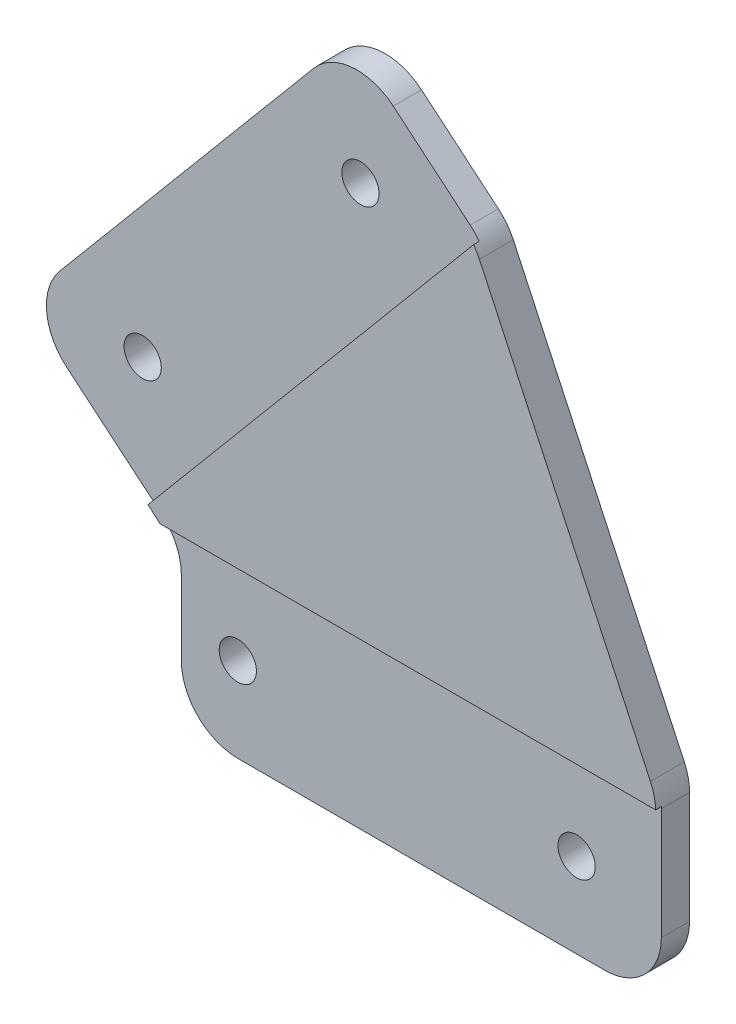
from build123d import *

# Parameters (mm, degrees)
EXTRUDE_1_DEPTH     = 3
SKETCH_2_R          = 1.65
CUT_EXTRUDE_1_DEPTH = 3
FILLET_2_R          = 5
SKETCH_3_W          = 44.5
SKETCH_3_H          = 15.05
CUT_EXTRUDE_2_DEPTH = 0.5


with BuildPart() as part:
    # ｽｹｯﾁ1 → ﾎﾞｽ - 押し出し1 (new body)
    with BuildSketch(Plane.XY):
        Polygon((-11.490666647, 9.641814145), (0, 0), (2.5, -2.097749078), (2.5, -16), (45, -16), (45, 0), (28.925442436, 34.47199994), (17.434775789, 44.113814086), align=None)
    extrude(amount=EXTRUDE_1_DEPTH)

    # ｽｹｯﾁ2 → ｶｯﾄ - 押し出し1 (cut)
    with BuildSketch(Plane.XY.offset(3)):
        with Locations((7.5, -8.5)):
            Circle(SKETCH_2_R)
        with Locations((-0.924426251, 10.566240396)):
            Circle(SKETCH_2_R)
        with Locations((18.35920204, 33.54757369)):
            Circle(SKETCH_2_R)
        with Locations((37.5, -8.5)):
            Circle(SKETCH_2_R)
    extrude(amount=-CUT_EXTRUDE_1_DEPTH, mode=Mode.SUBTRACT)

    # ﾌｨﾚｯﾄ2
    fillet_2_edges = [part.edges().sort_by_distance(p)[0] for p in [
        (-11.490666647, 9.641814145, 1.5),
        (17.434775789, 44.113814086, 1.5),
        (28.925442436, 34.47199994, 1.5),
        (45, 0, 1.5),
        (45, -16, 1.5),
        (2.5, -16, 1.5),
        (2.5, -2.097749078, 1.5),
    ]]
    fillet(fillet_2_edges, radius=FILLET_2_R)

    # ｽｹｯﾁ3 → ｶｯﾄ - 押し出し2 (cut)
    with BuildSketch(Plane.XY.offset(3)):
        Polygon((17.434775789, 44.113814086), (-12.133454256, 8.875769702), (-0.604485388, -0.798183824), (28.963744658, 34.43986056), align=None)
        with Locations((22.75, -8.475)):
            Rectangle(SKETCH_3_W, SKETCH_3_H)
    extrude(amount=-CUT_EXTRUDE_2_DEPTH, mode=Mode.SUBTRACT)


solid = part.part
